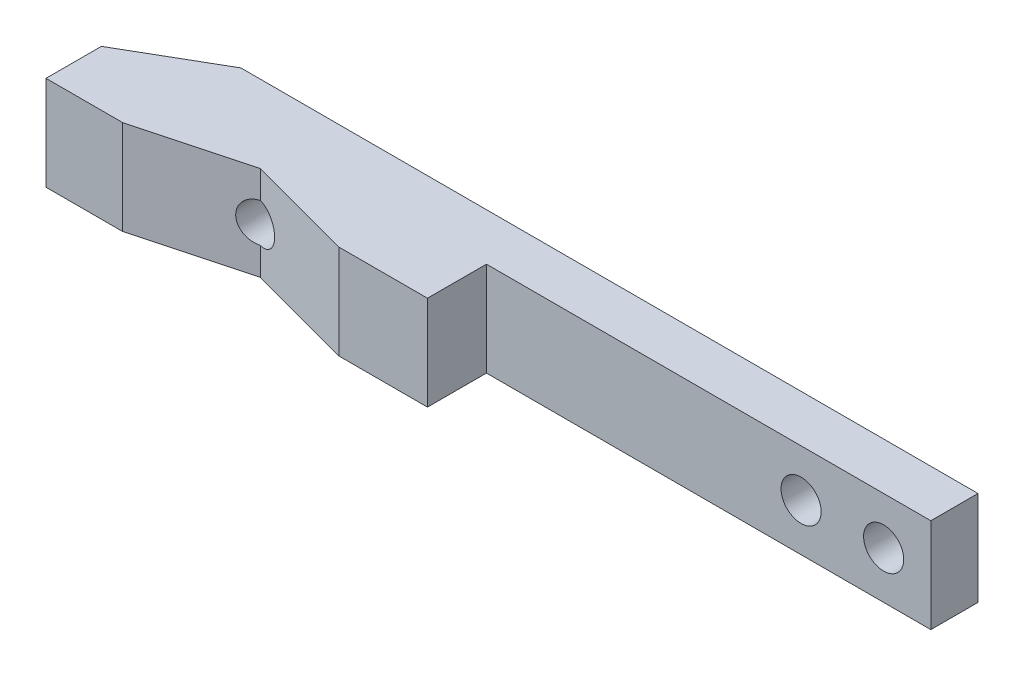
from build123d import *

# Parameters (mm, degrees)
BOSS_EXTRUDE2_DEPTH   = 8
M4_TAPPED_HOLE1_D     = 3.3
M4_TAPPED_HOLE1_DEPTH = 11.5
M4_TAPPED_HOLE1_TIP   = 0.991420021
SKETCH8_R             = 1.7
CUT_EXTRUDE1_DEPTH    = 10


with BuildPart() as part:
    # Sketch1 → Boss-Extrude2 (new body)
    with BuildSketch(Plane(origin=(0, 0, 0), x_dir=(1, 0, 0), z_dir=(0, 1, 0))):
        Polygon((35.397046685, 0.212206196), (35.397046685, -3.787793804), (-2.283249607, -3.787793804), (-2.283249607, -8.787793804), (-9.783249607, -8.787793804), (-18.892613672, -6.346947059), (-28.102933344, -8.814844777), (-34.602933344, -8.814844777), (-34.602933344, -4.117707659), (-27.103302555, 0.212206196), align=None)
    extrude(amount=BOSS_EXTRUDE2_DEPTH)

    # M4 Tapped Hole1
    with Locations(Plane(origin=(0, 0, -0.212206196), x_dir=(-1, 0, 0), z_dir=(0, 0, -1))):
        with Locations((18.892933344, 4)):
            Hole(M4_TAPPED_HOLE1_D / 2, depth=M4_TAPPED_HOLE1_DEPTH)
            with Locations((0, 0, -(M4_TAPPED_HOLE1_DEPTH + M4_TAPPED_HOLE1_TIP / 2))):  # 118° drill point
                Cone(0, M4_TAPPED_HOLE1_D / 2, M4_TAPPED_HOLE1_TIP, mode=Mode.SUBTRACT)

    # Sketch8 → Cut-Extrude1 (cut)
    with BuildSketch(Plane(origin=(0, 0, -0.212206196), x_dir=(-1, 0, 0), z_dir=(0, 0, -1))):
        with Locations((-31.397046685, 4)):
            Circle(SKETCH8_R)
        with Locations((-24.397046685, 4)):
            Circle(SKETCH8_R)
    extrude(amount=-CUT_EXTRUDE1_DEPTH, mode=Mode.SUBTRACT)


solid = part.part
